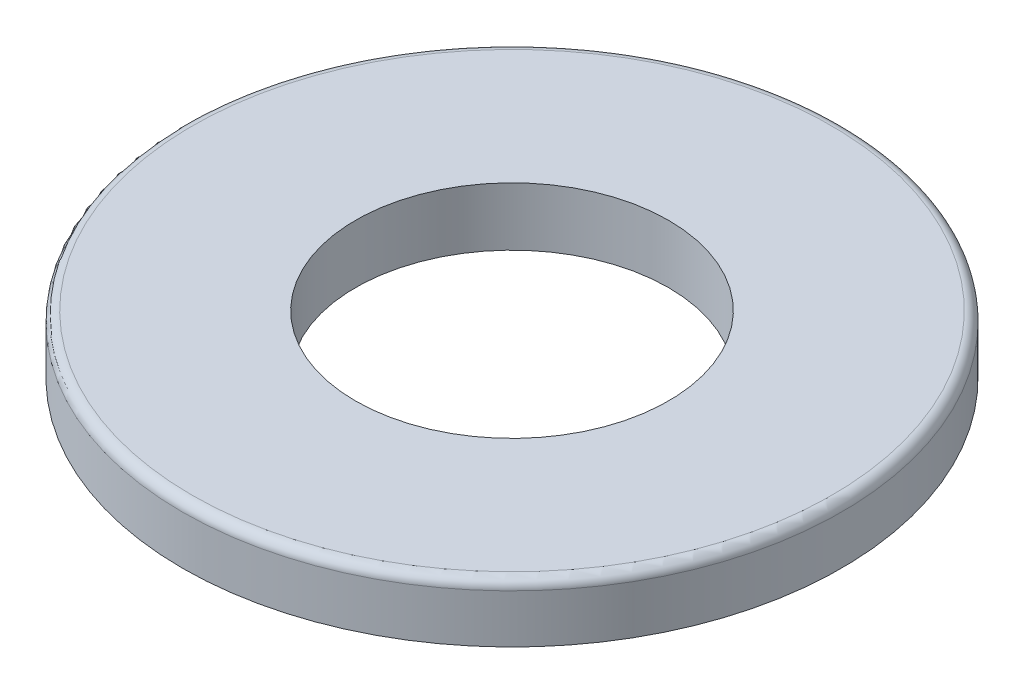
from build123d import *

# Parameters (mm, degrees)
SKETCH_1_R      = 16.95
SKETCH_1_R_2    = 8.05
EXTRUDE_1_DEPTH = 3
FILLET_1_R      = 0.5


with BuildPart() as part:
    # 草图1 → 凸台-拉伸1 (new body)
    with BuildSketch(Plane(origin=(0, 0, 0), x_dir=(1, 0, 0), z_dir=(0, 1, 0))):
        Circle(SKETCH_1_R)
        Circle(SKETCH_1_R_2, mode=Mode.SUBTRACT)
    extrude(amount=EXTRUDE_1_DEPTH)

    # 圆角1
    fillet_1_edges = [part.edges().sort_by_distance(p)[0] for p in [
        (-16.95, 3, 0),
    ]]
    fillet(fillet_1_edges, radius=FILLET_1_R)


solid = part.part
